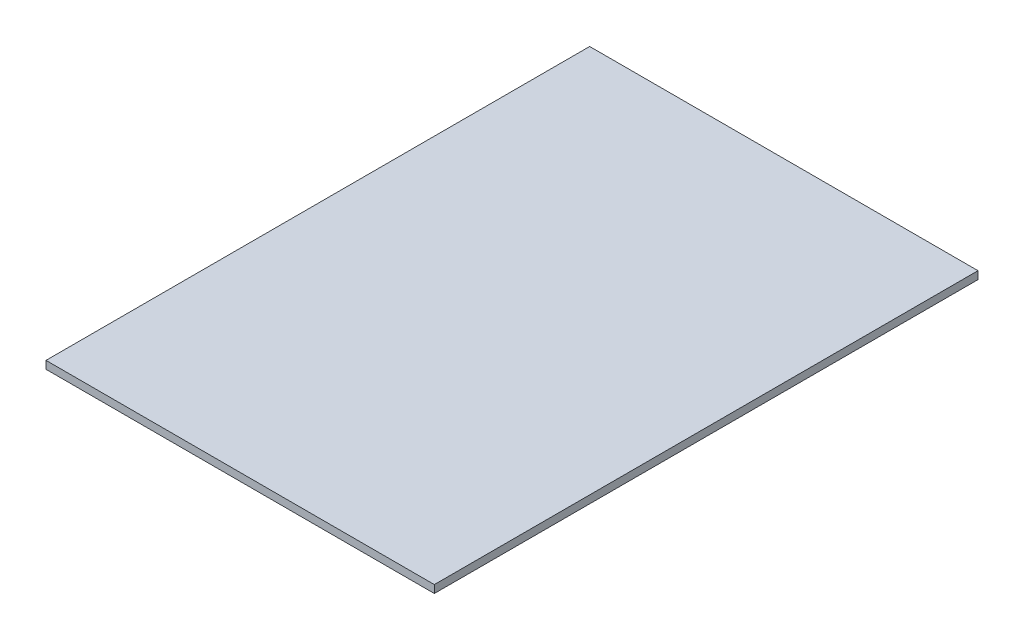
from build123d import *

# Parameters (mm, degrees)
SKETCH2_W           = 250
SKETCH2_H           = 350
BOSS_EXTRUDE1_DEPTH = 5


with BuildPart() as part:
    # Sketch2 → Boss-Extrude1 (new body)
    with BuildSketch(Plane(origin=(0, 0, 0), x_dir=(1, 0, 0), z_dir=(0, 1, 0))):
        with Locations((125, 175)):
            Rectangle(SKETCH2_W, SKETCH2_H)
    extrude(amount=BOSS_EXTRUDE1_DEPTH)


solid = part.part
